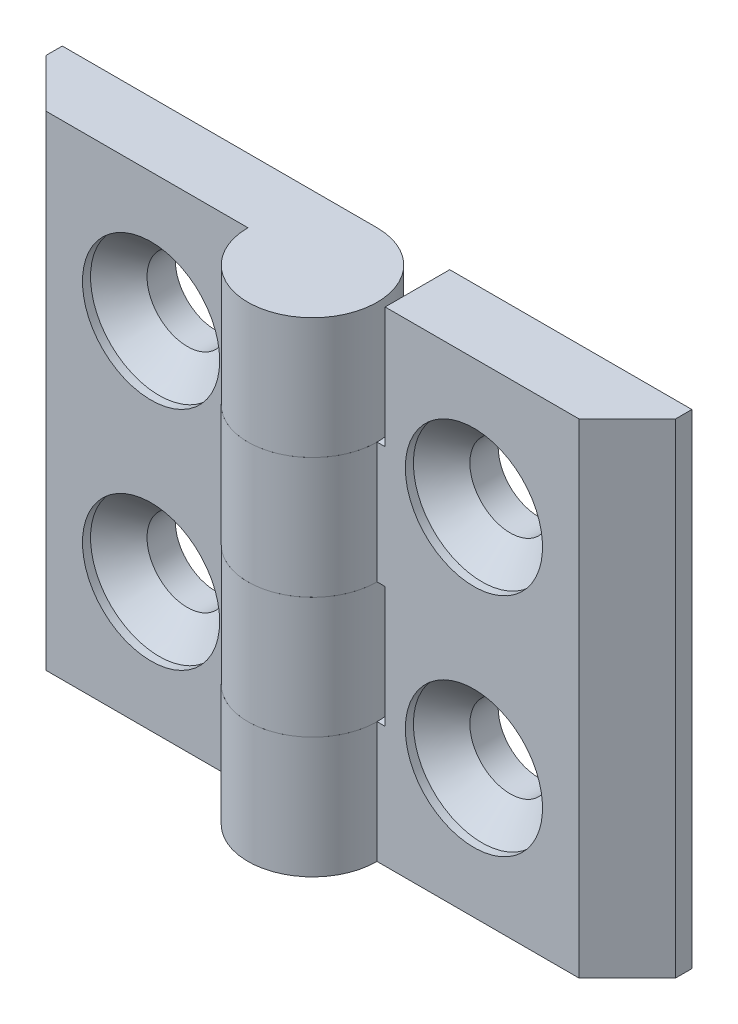
from build123d import *

# Parameters (mm, degrees)
EXTRUDE_1_DEPTH            = 15
SKETCH_3_W                 = 8.5
SKETCH_3_H                 = 7.5
CUT_EXTRUDE_1_DEPTH        = 5
CUT_EXTRUDE_1_DEPTH_BACK   = 5
HOLE_WIZARD_M41_AT_2_COUNT = 2
HOLE_WIZARD_M41_AT_2_PITCH = 14
PATTERN_CIRCULAR_1_COUNT   = 2


with BuildPart() as part:
    # Эскиз1 → Бобышка-Вытянуть1 (new body, symmetric)
    with BuildSketch(Plane(origin=(0, 0, 0), x_dir=(1, 0, 0), z_dir=(0, 1, 0))):
        with BuildLine():
            Line((0, 4), (-19.5, 4))
            Line((-19.5, 4), (-19.5, 3))
            Line((-19.5, 3), (-16.5, 0))
            Line((-16.5, 0), (-4, 0))
            ThreePointArc((-4, 0), (2.828427125, -2.828427125), (0, 4))
        make_face()
    extrude(amount=EXTRUDE_1_DEPTH, both=True)

    # Эскиз3 → Вырез-Вытянуть1 (cut, two sides)
    with BuildSketch(Plane.XY) as cut_extrude_1_sk:
        with Locations((-0.25, 3.75)):
            Rectangle(SKETCH_3_W, SKETCH_3_H)
        with Locations((-0.25, -11.25)):
            Rectangle(SKETCH_3_W, SKETCH_3_H)
    extrude(amount=CUT_EXTRUDE_1_DEPTH, mode=Mode.SUBTRACT)
    extrude(cut_extrude_1_sk.sketch, amount=-CUT_EXTRUDE_1_DEPTH_BACK, mode=Mode.SUBTRACT)

    # Эскиз6 → Зенковка для винта с полупотайной головкой M41 (revolve, cut)
    with BuildSketch(Plane(origin=(-10, 7, 0), x_dir=(0, -1, 0), z_dir=(1, 0, 0))):
        Polygon((0, 0), (0, 4), (2.5, 4), (2.5, 2.25), (4.25, 0.5), (4.25, 0), align=None)
    hole_wizard_m41 = revolve(axis=Axis((-10, 7, 6.35), (0, 0, -1)), mode=Mode.SUBTRACT)

    # Зенковка для винта с полупотайной головкой M41 at 2: Зенковка для винта с полупотайной головкой M41 ×2
    with Locations(*[(0, -i * HOLE_WIZARD_M41_AT_2_PITCH, 0) for i in range(1, HOLE_WIZARD_M41_AT_2_COUNT)]):
        add(hole_wizard_m41, mode=Mode.SUBTRACT)


with BuildPart() as pattern_circular_1_1:
    # Круговой массив1: pattern copy
    add(part.part.rotate(Axis((0, 0, 0), (0, 0, 1)), 1 * 360 / PATTERN_CIRCULAR_1_COUNT))


solid = Compound([part.part, pattern_circular_1_1.part])
